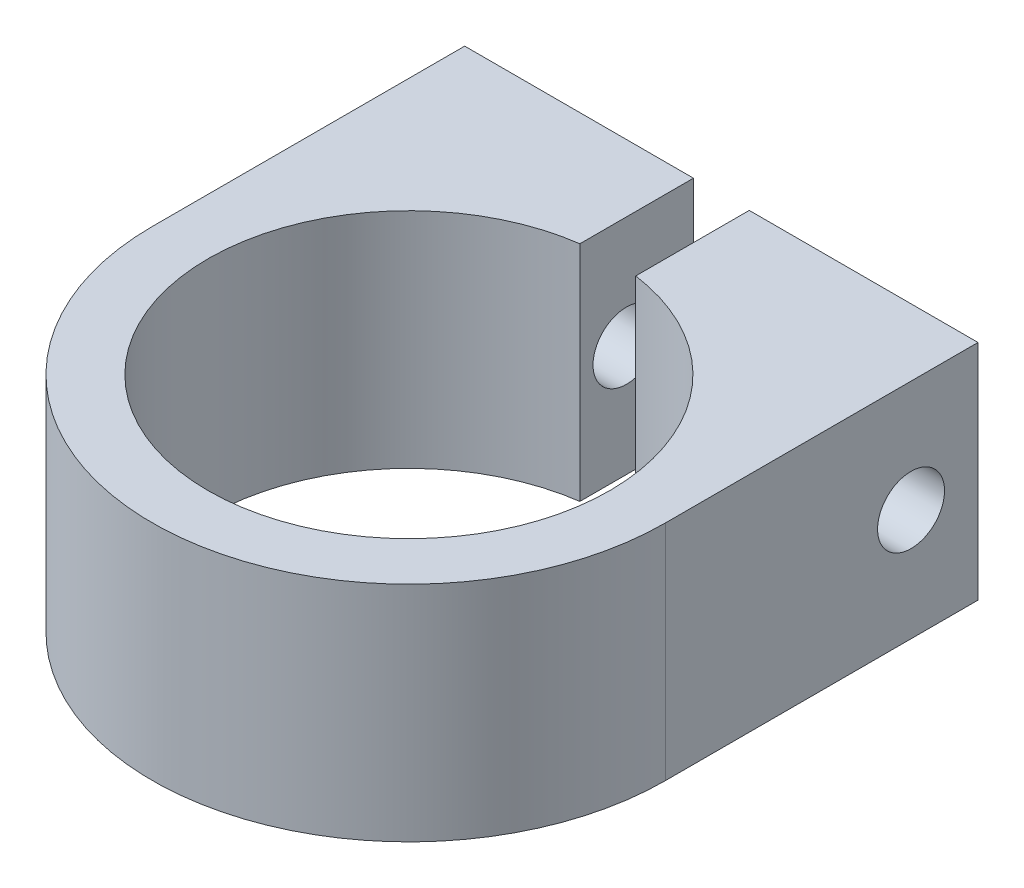
from build123d import *

# Parameters (mm, degrees)
BOSS_EXTRU_1_DEPTH      = 20
ESQUISSE2_R             = 3
ENL_V_MAT_EXTRU_1_DEPTH = 47
ENL_V_MAT_EXTRU_2_DEPTH = 10


with BuildPart() as part:
    # Esquisse1 → Boss.-Extru.1 (new body)
    with BuildSketch(Plane(origin=(0, 0, 0), x_dir=(1, 0, 0), z_dir=(0, 1, 0))):
        with BuildLine():
            Line((-23, 0), (-23, 28))
            Line((-23, 28), (-2.5, 28))
            Line((-2.5, 28), (-2.5, 17.82554347))
            ThreePointArc((-2.5, 17.82554347), (0, -18), (2.5, 17.82554347))
            Line((2.5, 17.82554347), (2.5, 28))
            Line((2.5, 28), (23, 28))
            Line((23, 28), (23, 0))
            ThreePointArc((23, 0), (0, -23), (-23, 0))
        make_face()
    extrude(amount=BOSS_EXTRU_1_DEPTH)

    # Esquisse2 → Enlèv. mat.-Extru.1 (cut, through all)
    with BuildSketch(Plane(origin=(23, 0, 0), x_dir=(0, 0, -1), z_dir=(1, 0, 0))):
        with Locations((22, 10)):
            Circle(ESQUISSE2_R)
    extrude(amount=-ENL_V_MAT_EXTRU_1_DEPTH, mode=Mode.SUBTRACT)

    # Esquisse3 → Enlèv. mat.-Extru.2 (cut)
    with BuildSketch(Plane.ZY.offset(23)):
        Polygon((-22, 4.226497308), (-17, 7.113248654), (-17, 12.886751346), (-22, 15.773502692), (-27, 12.886751346), (-27, 7.113248654), align=None)
    extrude(amount=-ENL_V_MAT_EXTRU_2_DEPTH, mode=Mode.SUBTRACT)


solid = part.part
